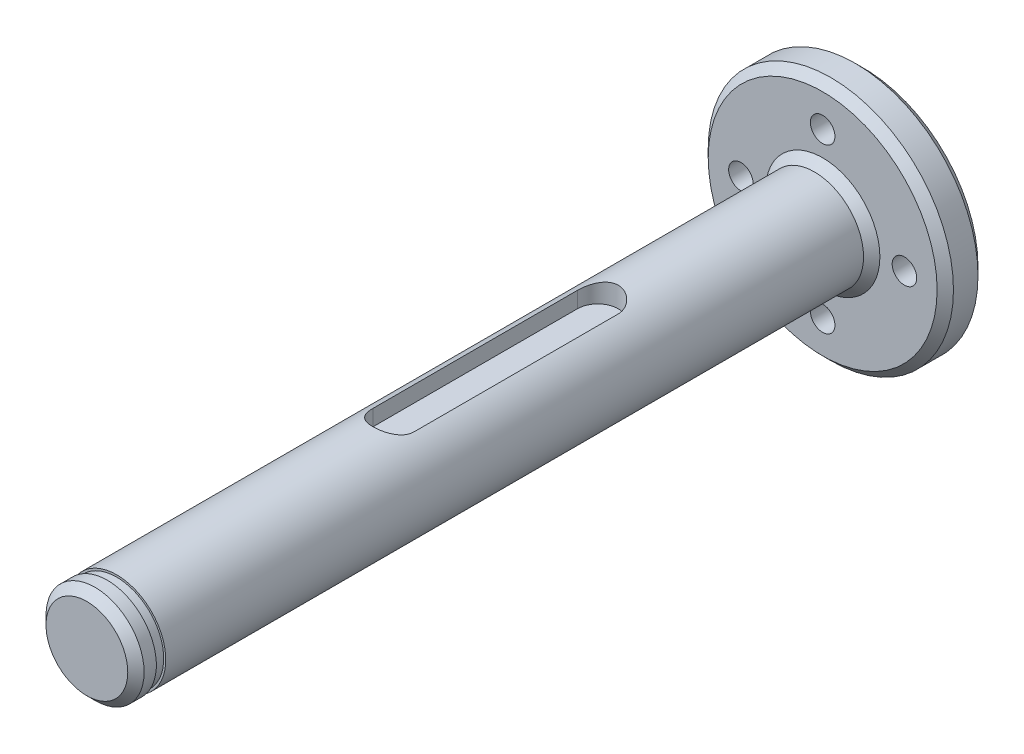
from build123d import *

# Parameters (mm, degrees)
SKETCH1_R                 = 15
BOSS_EXTRUDE1_DEPTH       = 5
SKETCH4_R                 = 1.5
CUT_EXTRUDE2_DEPTH        = 1
CUT_EXTRUDE2_DEPTH_BACK   = 6
SKETCH6_R                 = 6
BOSS_EXTRUDE2_DEPTH       = 90
CHAMFER1_SIZE             = 1
CUT_EXTRUDE3_DEPTH        = 2.5
SKETCH8_W                 = 0.25
SKETCH8_H                 = 1.15
F_5_0MM_DOWEL_HOLE1_D     = 5
F_5_0MM_DOWEL_HOLE1_DEPTH = 7.5
F_5_0MM_DOWEL_HOLE1_TIP   = 1.502151548
CHAMFER2_SIZE             = 1


with BuildPart() as part:
    # Sketch1 → Boss-Extrude1 (new body)
    with BuildSketch(Plane.XY):
        Circle(SKETCH1_R)
    extrude(amount=BOSS_EXTRUDE1_DEPTH)

    # Sketch4 → Cut-Extrude2 (cut, two sides)
    with BuildSketch(Plane(origin=(0, 0, 0), x_dir=(-1, 0, 0), z_dir=(0, 0, -1))) as cut_extrude2_sk:
        with Locations((10, 0)):
            Circle(SKETCH4_R)
        with Locations((0, -10)):
            Circle(SKETCH4_R)
        with Locations((-10, 0)):
            Circle(SKETCH4_R)
        with Locations((0, 10)):
            Circle(SKETCH4_R)
    extrude(amount=CUT_EXTRUDE2_DEPTH, mode=Mode.SUBTRACT)
    extrude(cut_extrude2_sk.sketch, amount=-CUT_EXTRUDE2_DEPTH_BACK, mode=Mode.SUBTRACT)

    # Sketch6 → Boss-Extrude2 (add)
    with BuildSketch(Plane.XY.offset(5)):
        Circle(SKETCH6_R)
    extrude(amount=BOSS_EXTRUDE2_DEPTH)

    # Chamfer1
    chamfer1_edges = [part.edges().sort_by_distance(p)[0] for p in [
        (-15, 0, 0),
        (-6, 0, 5),
        (-6, 0, 95),
        (-15, 0, 5),
    ]]
    chamfer(chamfer1_edges, length=CHAMFER1_SIZE)

    # Sketch7 → Cut-Extrude3 (cut)
    with BuildSketch(Plane(origin=(0, 6, 0), x_dir=(1, 0, 0), z_dir=(0, 1, 0))):
        with BuildLine():
            Line((-2.5, -57.5), (-2.5, -32.5))
            ThreePointArc((-2.5, -32.5), (0, -30), (2.5, -32.5))
            Line((2.5, -32.5), (2.5, -57.5))
            ThreePointArc((2.5, -57.5), (0, -60), (-2.5, -57.5))
        make_face()
    extrude(amount=-CUT_EXTRUDE3_DEPTH, mode=Mode.SUBTRACT)

    # Sketch8 → Cut-Revolve1 (revolve, cut)
    with BuildSketch(Plane(origin=(0, 0, 0), x_dir=(1, 0, 0), z_dir=(0, 1, 0))):
        with Locations((-5.875, -91.925)):
            Rectangle(SKETCH8_W, SKETCH8_H)
    revolve(axis=Axis((0, 0, 0), (0, 0, 1)), mode=Mode.SUBTRACT)

    # Ø5.0mm Dowel Hole1
    with Locations(Plane(origin=(0, 0, 0), x_dir=(-1, 0, 0), z_dir=(0, 0, -1))):
        with Locations((0, 0)):
            Hole(F_5_0MM_DOWEL_HOLE1_D / 2, depth=F_5_0MM_DOWEL_HOLE1_DEPTH)
            with Locations((0, 0, -(F_5_0MM_DOWEL_HOLE1_DEPTH + F_5_0MM_DOWEL_HOLE1_TIP / 2))):  # 118° drill point
                Cone(0, F_5_0MM_DOWEL_HOLE1_D / 2, F_5_0MM_DOWEL_HOLE1_TIP, mode=Mode.SUBTRACT)

    # Chamfer2
    chamfer2_edges = [part.edges().sort_by_distance(p)[0] for p in [
        (-2.5, 0, 0),
    ]]
    chamfer(chamfer2_edges, length=CHAMFER2_SIZE)


solid = part.part
